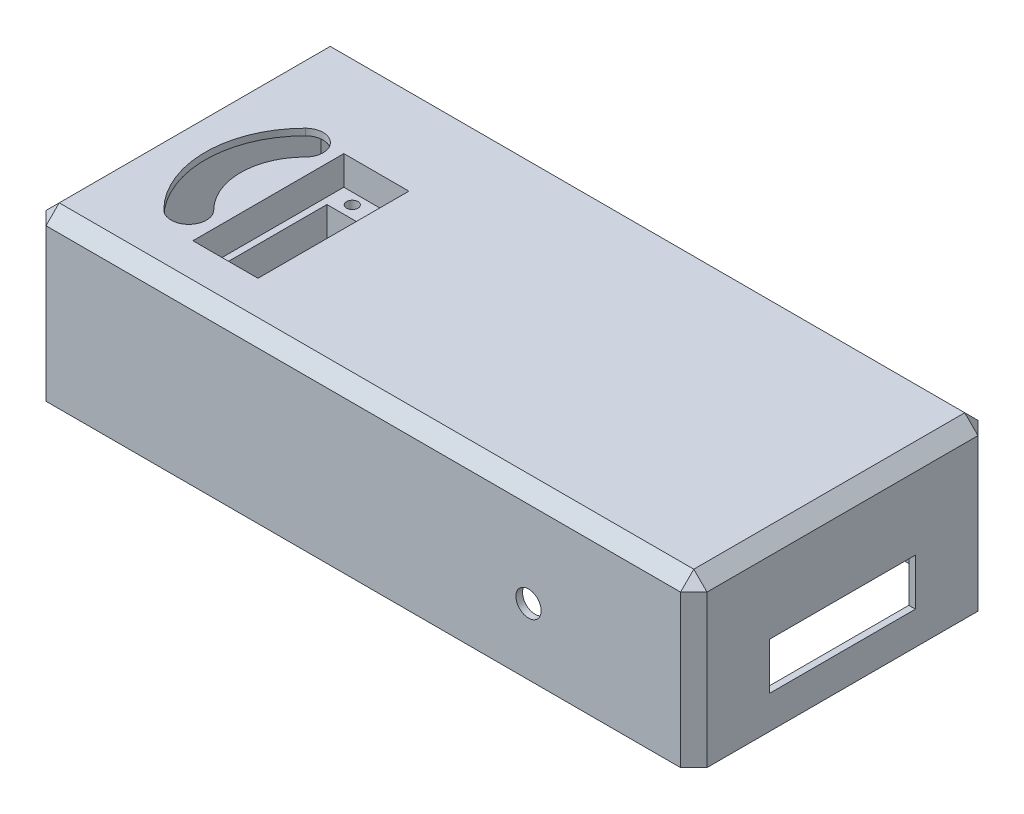
from build123d import *

# Parameters (mm, degrees)
SKETCH1_W           = 254
SKETCH1_H           = 114.3
BOSS_EXTRUDE1_DEPTH = 63.5
CHAMFER1_SIZE       = 5.08
SKETCH4_W           = 25
SKETCH4_H           = 58
CUT_EXTRUDE2_DEPTH  = 11.189999972
SHELL3_T            = -2.54
SKETCH6_W           = 30.08
SKETCH6_H           = 63.08
BOSS_EXTRUDE2_DEPTH = 12.7
SKETCH5_W           = 20
SKETCH5_H           = 40
CUT_EXTRUDE5_DEPTH  = 53.310000028
SKETCH7_R           = 4.85
CUT_EXTRUDE6_DEPTH  = 25.4
SKETCH8_R           = 2.2
CUT_EXTRUDE7_DEPTH  = 53.310000028
CUT_EXTRUDE9_START  = -127
CUT_EXTRUDE9_DEPTH  = 38.1
CUT_EXTRUDE10_DEPTH = 64.5
SKETCH12_W          = 56
SKETCH12_H          = 18
CUT_EXTRUDE12_DEPTH = 2.54


with BuildPart() as part:
    # Sketch1 → Boss-Extrude1 (new body)
    with BuildSketch(Plane(origin=(0, 0, 0), x_dir=(1, 0, 0), z_dir=(0, 1, 0))):
        with Locations((-127, 57.15)):
            Rectangle(SKETCH1_W, SKETCH1_H)
    extrude(amount=BOSS_EXTRUDE1_DEPTH)

    # Chamfer1
    chamfer1_edges = [part.edges().sort_by_distance(p)[0] for p in [
        (-254, 63.5, -57.15),
        (-127, 63.5, 0),
        (0, 63.5, -57.15),
        (0, 31.75, 0),
        (-254, 31.75, 0),
        (-254, 31.75, -114.3),
        (0, 31.75, -114.3),
        (-127, 63.5, -114.3),
    ]]
    chamfer(chamfer1_edges, length=CHAMFER1_SIZE)

    # Sketch4 → Cut-Extrude2 (cut)
    with BuildSketch(Plane(origin=(0, 63.5, 0), x_dir=(1, 0, 0), z_dir=(0, 1, 0))):
        with Locations((-198.12, 47.15)):
            Rectangle(SKETCH4_W, SKETCH4_H)
    extrude(amount=-CUT_EXTRUDE2_DEPTH, mode=Mode.SUBTRACT)

    # Shell3
    shell3_openings = [part.faces().sort_by_distance(p)[0] for p in [
        (-127, 0, -57.15),
    ]]
    offset(amount=SHELL3_T, openings=shell3_openings, kind=Kind.INTERSECTION)

    # Sketch6 → Boss-Extrude2 (add)
    with BuildSketch(Plane.XZ.offset(-49.770000028)):
        with Locations((-198.12, -47.15)):
            Rectangle(SKETCH6_W, SKETCH6_H)
    extrude(amount=BOSS_EXTRUDE2_DEPTH)

    # Sketch5 → Cut-Extrude5 (cut, through all)
    with BuildSketch(Plane(origin=(0, 52.310000028, 0), x_dir=(1, 0, 0), z_dir=(0, 1, 0))):
        with Locations((-198.12, 47.15)):
            Rectangle(SKETCH5_W, SKETCH5_H)
    extrude(amount=-CUT_EXTRUDE5_DEPTH, mode=Mode.SUBTRACT)

    # Sketch7 → Cut-Extrude6 (cut)
    with BuildSketch(Plane.XY):
        with Locations((-63.5, 25.4)):
            Circle(SKETCH7_R)
    extrude(amount=-CUT_EXTRUDE6_DEPTH, mode=Mode.SUBTRACT)

    # Sketch8 → Cut-Extrude7 (cut, through all)
    with BuildSketch(Plane(origin=(0, 52.310000028, 0), x_dir=(1, 0, 0), z_dir=(0, 1, 0))):
        with Locations((-203.12, 71.9)):
            Circle(SKETCH8_R)
        with Locations((-193.12, 71.9)):
            Circle(SKETCH8_R)
        with Locations((-193.12, 22.4)):
            Circle(SKETCH8_R)
        with Locations((-203.12, 22.4)):
            Circle(SKETCH8_R)
    extrude(amount=-CUT_EXTRUDE7_DEPTH, mode=Mode.SUBTRACT)

    # Sketch9 → Cut-Extrude9 (cut, symmetric)
    with BuildSketch(Plane(origin=(0, 0, 0), x_dir=(0, 0, -1), z_dir=(1, 0, 0)).offset(CUT_EXTRUDE9_START)):
        Polygon((2.54, 0), (3.81, 0), (3.81, 3.81), (1.27, 3.81), (2.54, 1.27), align=None)
    cut_extrude9 = extrude(amount=CUT_EXTRUDE9_DEPTH, both=True, mode=Mode.SUBTRACT)

    # Mirror1: Cut-Extrude9 across plane
    add(cut_extrude9.mirror(Plane.XY.offset(-57.15)), mode=Mode.SUBTRACT)

    # Sketch10 → Cut-Extrude10 (cut, through all)
    with BuildSketch(Plane(origin=(0, 63.5, 0), x_dir=(1, 0, 0), z_dir=(0, 1, 0))):
        with BuildLine():
            ThreePointArc((-226.45590841, 77.22804441), (-237.729116487, 50.012112577), (-226.45590841, 22.796180745))
            ThreePointArc((-226.45590841, 22.796180745), (-216.854647797, 22.796180745), (-216.854647797, 32.397441358))
            ThreePointArc((-216.854647797, 32.397441358), (-224.150883513, 50.012112577), (-216.854647797, 67.626783797))
            ThreePointArc((-216.854647797, 67.626783797), (-216.854647797, 77.22804441), (-226.45590841, 77.22804441))
        make_face()
    extrude(amount=-CUT_EXTRUDE10_DEPTH, mode=Mode.SUBTRACT)

    # Sketch12 → Cut-Extrude12 (cut)
    with BuildSketch(Plane(origin=(0, 0, 0), x_dir=(0, 0, -1), z_dir=(1, 0, 0))):
        with Locations((57.15, 21.7)):
            Rectangle(SKETCH12_W, SKETCH12_H)
    extrude(amount=-CUT_EXTRUDE12_DEPTH, mode=Mode.SUBTRACT)


solid = part.part
